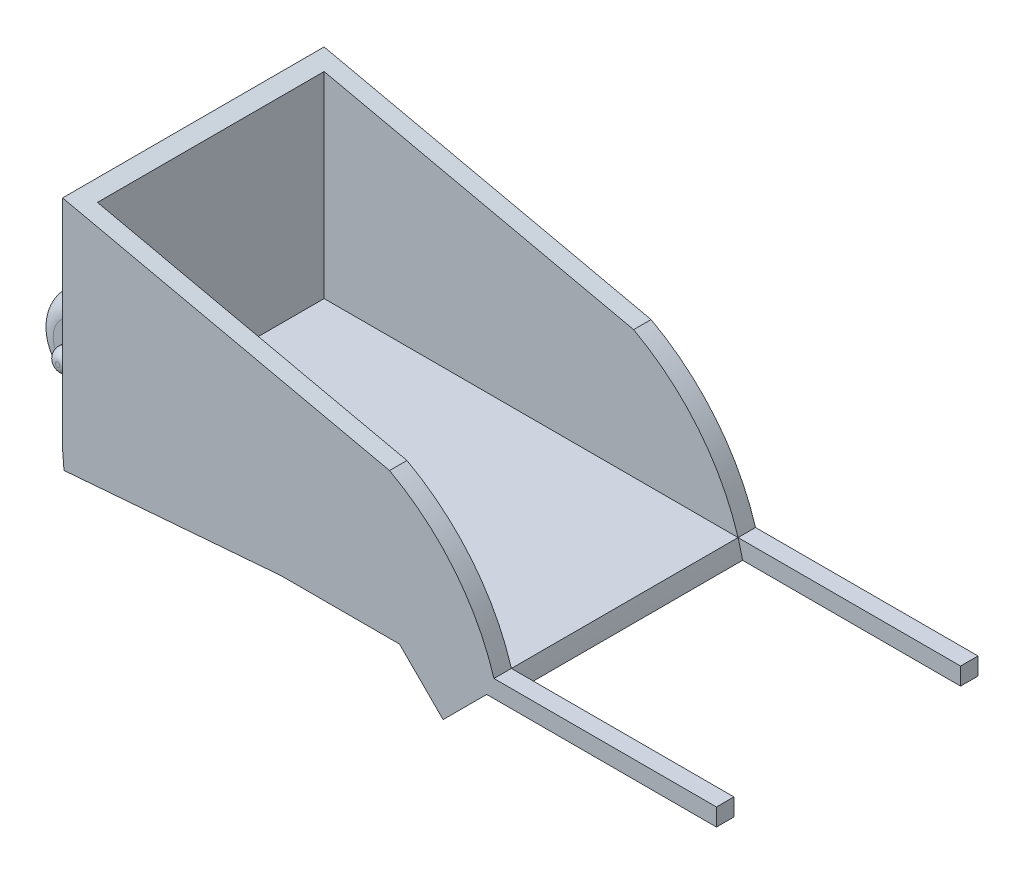
from build123d import *

# Parameters (mm, degrees)
SKETCH2_W                  = 50
SKETCH2_H                  = 30
BOSS_EXTRUDE1_DEPTH        = 25
CUT_EXTRUDE2_DEPTH         = 31
SKETCH7_W                  = 26
SKETCH7_H                  = 21
CUT_EXTRUDE3_DEPTH         = 48
SKETCH8_W                  = 7.000000004
SKETCH8_H                  = 26
CUT_EXTRUDE6_DEPTH         = 3
CUT_EXTRUDE6_DEPTH_BACK    = 10
SKETCH9_W                  = 2
SKETCH9_H                  = 2
BOSS_EXTRUDE2_DEPTH        = 25
BOSS_EXTRUDE2_DEPTH_BACK   = 25
BOSS_EXTRUDE2_2_DEPTH      = 25
BOSS_EXTRUDE2_2_DEPTH_BACK = 25
BOSS_EXTRUDE3_DEPTH        = 30
CUT_EXTRUDE7_DEPTH         = 30
SKETCH13_R                 = 5
BOSS_EXTRUDE4_DEPTH        = 2.5
BOSS_EXTRUDE4_DEPTH_BACK   = 2.5
SKETCH14_R                 = 1.257458731
BOSS_EXTRUDE5_DEPTH        = 2.5
BOSS_EXTRUDE5_DEPTH_BACK   = 7.5
FILLET3_R                  = 2
FILLET4_R                  = 2
FILLET7_R                  = 1
FILLET8_R                  = 1
BOSS_EXTRUDE6_DEPTH        = 5
BOSS_EXTRUDE7_DEPTH        = 5


with BuildPart() as part:
    # Sketch2 → Boss-Extrude1 (new body)
    with BuildSketch(Plane(origin=(0, 0, 0), x_dir=(1, 0, 0), z_dir=(0, 1, 0))):
        Rectangle(SKETCH2_W, SKETCH2_H)
    extrude(amount=BOSS_EXTRUDE1_DEPTH)

    # Sketch3 → Cut-Extrude2 (cut, through all)
    with BuildSketch(Plane.XY.offset(15)):
        with BuildLine():
            Line((-25, 25), (12.5, 16.66666667))
            ThreePointArc((12.5, 16.66666667), (20.568813143, 9.697443192), (25, 0))
            Line((25, 0), (25, 25))
            Line((25, 25), (-25, 25))
        make_face()
    extrude(amount=-CUT_EXTRUDE2_DEPTH, mode=Mode.SUBTRACT)

    # Sketch7 → Cut-Extrude3 (cut)
    with BuildSketch(Plane.ZY.offset(-25)):
        with Locations((0, 12.5)):
            Rectangle(SKETCH7_W, SKETCH7_H)
    extrude(amount=CUT_EXTRUDE3_DEPTH, mode=Mode.SUBTRACT)

    # Sketch8 → Cut-Extrude6 (cut, two sides)
    with BuildSketch(Plane.XZ.offset(-23)) as cut_extrude6_sk:
        with Locations((-19.499999998, 0)):
            Rectangle(SKETCH8_W, SKETCH8_H)
    extrude(amount=CUT_EXTRUDE6_DEPTH, mode=Mode.SUBTRACT)
    extrude(cut_extrude6_sk.sketch, amount=-CUT_EXTRUDE6_DEPTH_BACK, mode=Mode.SUBTRACT)



with BuildPart() as body_2:
    # Sketch9 → Boss-Extrude2 (new body, two sides)
    with BuildSketch(Plane.ZY.offset(-25)) as boss_extrude2_sk:
        with Locations((14, 1)):
            Rectangle(SKETCH9_W, SKETCH9_H)
    extrude(amount=BOSS_EXTRUDE2_DEPTH)
    extrude(boss_extrude2_sk.sketch, amount=-BOSS_EXTRUDE2_DEPTH_BACK)


with BuildPart() as body_3:
    # Sketch9 → Boss-Extrude2 2 (new body, two sides)
    with BuildSketch(Plane.ZY.offset(-25)) as boss_extrude2_2_sk:
        with Locations((-14, 1)):
            Rectangle(SKETCH9_W, SKETCH9_H)
    extrude(amount=BOSS_EXTRUDE2_2_DEPTH)
    extrude(boss_extrude2_2_sk.sketch, amount=-BOSS_EXTRUDE2_2_DEPTH_BACK)


with BuildPart() as part_1:
    add(part.part)

    add(body_2.part)  # Boss-Extrude3 merges body 2

    add(body_3.part)  # Boss-Extrude3 merges body 3
    # Sketch10 → Boss-Extrude3 (add)
    with BuildSketch(Plane.XY.offset(15)):
        Polygon((-25, 0), (-35.654566136, -0.855106022), (-35.494566136, -2.848695749), (-27.301895797, -2.191174678), (0, 0), align=None)
    extrude(amount=-BOSS_EXTRUDE3_DEPTH)

    # Sketch11 → Cut-Extrude7 (cut)
    with BuildSketch(Plane(origin=(-0.16, 1.993589727, 0), x_dir=(0.996794864, 0.08, 0), z_dir=(-0.08, 0.996794864, 0))):
        Polygon((-24.919871589, -15), (-35.608696868, 0), (-35.608696868, -15), align=None)
        Polygon((-35.608696868, 0), (-24.919871589, 15), (-35.608696868, 15), align=None)
    extrude(amount=-CUT_EXTRUDE7_DEPTH, mode=Mode.SUBTRACT)

    # Sketch13 → Boss-Extrude4 (add, two sides)
    with BuildSketch(Plane(origin=(0, 0, 0), x_dir=(-0.08, 0.996794864, 0), z_dir=(0, 0, 1))) as boss_extrude4_sk:
        with Locations((1, 35.608696868)):
            Circle(SKETCH13_R)
    extrude(amount=BOSS_EXTRUDE4_DEPTH)
    extrude(boss_extrude4_sk.sketch, amount=-BOSS_EXTRUDE4_DEPTH_BACK)

    # Sketch14 → Boss-Extrude5 (add, two sides)
    with BuildSketch(Plane.XY.offset(2.5)) as boss_extrude5_sk:
        with Locations((-35.574566136, -1.851900886)):
            Circle(SKETCH14_R)
    extrude(amount=BOSS_EXTRUDE5_DEPTH)
    extrude(boss_extrude5_sk.sketch, amount=-BOSS_EXTRUDE5_DEPTH_BACK)

    # Fillet3
    fillet3_edges = [part_1.edges().sort_by_distance(p)[0] for p in [
        (-40.558540453, -2.251900886, 2.5),
    ]]
    fillet(fillet3_edges, radius=FILLET3_R)

    # Fillet4
    fillet4_edges = [part_1.edges().sort_by_distance(p)[0] for p in [
        (-40.558540453, -2.251900886, -2.5),
    ]]
    fillet(fillet4_edges, radius=FILLET4_R)

    # Fillet7
    fillet7_edges = [part_1.edges().sort_by_distance(p)[0] for p in [
        (-36.832024866, -1.851900886, 5),
    ]]
    fillet(fillet7_edges, radius=FILLET7_R)

    # Fillet8
    fillet8_edges = [part_1.edges().sort_by_distance(p)[0] for p in [
        (-36.832024866, -1.851900886, -5),
    ]]
    fillet(fillet8_edges, radius=FILLET8_R)

    # Sketch15 → Boss-Extrude6 (add)
    with BuildSketch(Plane.XY.offset(15)):
        Polygon((23.647734322, 0), (18.647734702, -5), (13.647734322, 0), align=None)
    extrude(amount=-BOSS_EXTRUDE6_DEPTH)

    # Sketch16 → Boss-Extrude7 (add)
    with BuildSketch(Plane(origin=(0, 0, -15), x_dir=(-1, 0, 0), z_dir=(0, 0, -1))):
        Polygon((-23.647734322, 0), (-18.647734702, -5), (-13.647734322, 0), align=None)
    extrude(amount=-BOSS_EXTRUDE7_DEPTH)


solid = part_1.part
